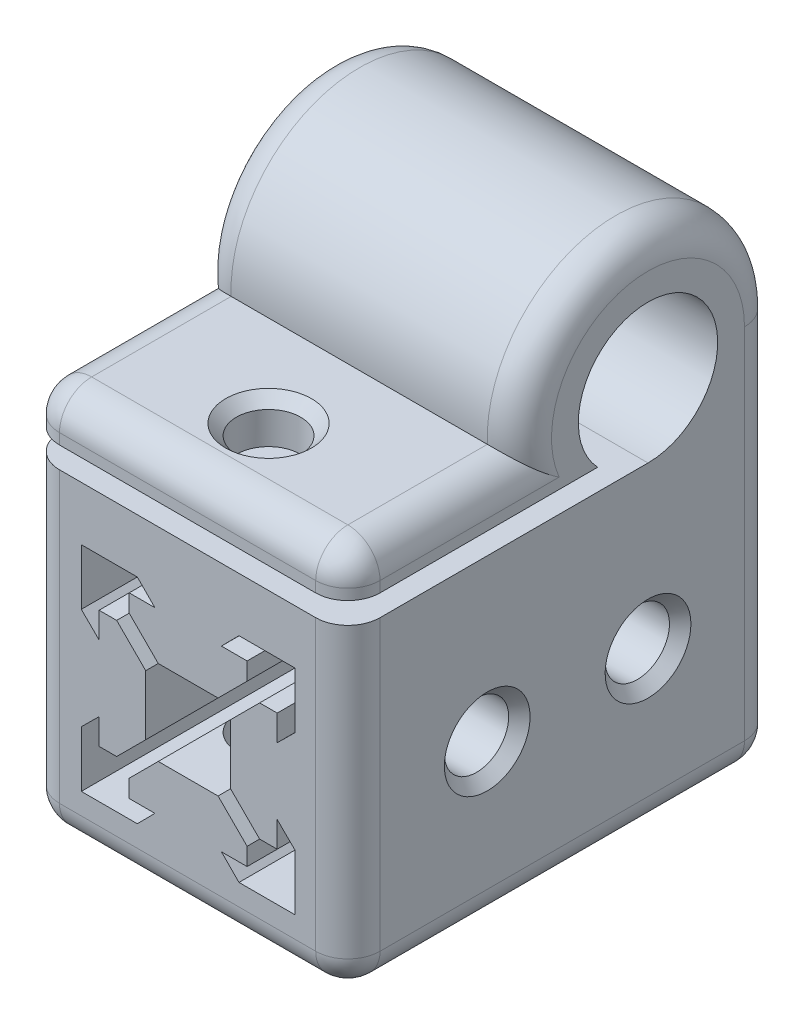
from build123d import *

# Parameters (mm, degrees)
BOSS_EXTRUDE1_DEPTH = 40
BOSS_EXTRUDE3_DEPTH = 29.899298
SKETCH3_R           = 3
CUT_EXTRUDE1_DEPTH  = 30.899298
SKETCH4_R           = 3
CUT_EXTRUDE2_DEPTH  = 38.007847
FILLET1_R           = 3
CHAMFER1_SIZE       = 1


with BuildPart() as part:
    # Sketch1 → Boss-Extrude1 (new body)
    with BuildSketch(Plane.XY):
        Polygon((0, 15), (14.899298, 15), (14.899298, -14.949649), (-15, -14.949649), (-15, 15), align=None)
        Polygon((-9.966433, 9.966433), (-4.741433, 9.966433), (-3.1, 8.307461), (-5.5, 8.307461), (-5.5, 6.667461), (-2.79, 3.957461), (2.79, 3.957461), (5.5, 6.667461), (5.5, 8.307461), (3.1, 8.307461), (4.741433, 9.966433), (9.966433, 9.966433), (9.966433, 4.741433), (8.307461, 3.1), (8.307461, 5.5), (6.667461, 5.5), (3.957461, 2.79), (3.957461, -2.79), (6.667461, -5.5), (8.307461, -5.5), (8.307461, -3.1), (9.966433, -4.741433), (9.966433, -9.966433), (4.741433, -9.966433), (3.1, -8.307461), (5.5, -8.307461), (5.5, -6.667461), (2.79, -3.957461), (-2.79, -3.957461), (-5.5, -6.667461), (-5.5, -8.307461), (-3.1, -8.307461), (-4.741433, -9.966433), (-9.966433, -9.966433), (-9.966433, -4.741433), (-8.307461, -3.1), (-8.307461, -5.5), (-6.667461, -5.5), (-3.957461, -2.79), (-3.957461, 2.79), (-6.667461, 5.5), (-8.307461, 5.5), (-8.307461, 3.1), (-9.966433, 4.741433), align=None, mode=Mode.SUBTRACT)
    extrude(amount=BOSS_EXTRUDE1_DEPTH)

    # Sketch5 → Boss-Extrude3 (add, through all)
    with BuildSketch(Plane.ZY.offset(15)):
        with BuildLine():
            Line((0, 21.5), (0, 15))
            Line((0, 15), (12, 15))
            ThreePointArc((12, 15), (9.45049, 27.47913), (16.690416, 17))
            Line((16.690416, 17), (27.804488, 17))
            Line((27.804488, 17), (40, 17))
            Line((40, 17), (40, 21))
            Line((40, 21), (23.989579, 21))
            ThreePointArc((23.989579, 21), (12.250054, 33.497394), (0, 21.5))
        make_face()
    extrude(amount=-BOSS_EXTRUDE3_DEPTH)

    # Sketch3 → Cut-Extrude1 (cut, through all)
    with BuildSketch(Plane.ZY.offset(15)):
        with Locations((12, 0)):
            Circle(SKETCH3_R)
        with Locations((27, 0)):
            Circle(SKETCH3_R)
    extrude(amount=-CUT_EXTRUDE1_DEPTH, mode=Mode.SUBTRACT)

    # Sketch4 → Cut-Extrude2 (cut, through all)
    with BuildSketch(Plane(origin=(0, 22.058198, 0), x_dir=(1, 0, 0), z_dir=(0, 1, 0))):
        with Locations((0, -32.5)):
            Circle(SKETCH4_R)
    extrude(amount=-CUT_EXTRUDE2_DEPTH, mode=Mode.SUBTRACT)

    # Fillet1
    fillet1_edges = [part.edges().sort_by_distance(p)[0] for p in [
        (-0.050351, -14.949649, 40),
        (14.899298, 0.025175, 40),
        (14.899298, 33.497394, 12.250054),
        (14.899298, 21, 31.994789),
        (14.899298, 19, 40),
        (-0.050351, 21, 40),
        (-15, 19, 40),
        (-15, 21, 31.994789),
        (-15, 33.497394, 12.250054),
        (14.899298, 0.025175, 0),
        (-0.050351, -14.949649, 0),
        (-15, 3.275175, 0),
        (-15, 0.025175, 40),
        (14.899298, -14.949649, 20),
        (-15, -14.949649, 20),
    ]]
    fillet(fillet1_edges, radius=FILLET1_R)

    # Chamfer1
    chamfer1_edges = [part.edges().sort_by_distance(p)[0] for p in [
        (14.899298, 0, 9),
        (-15, 0, 9),
        (14.899298, 0, 24),
        (-15, 0, 24),
        (-3, -14.949649, 32.5),
        (-3, 21, 32.5),
    ]]
    chamfer(chamfer1_edges, length=CHAMFER1_SIZE)


solid = part.part
